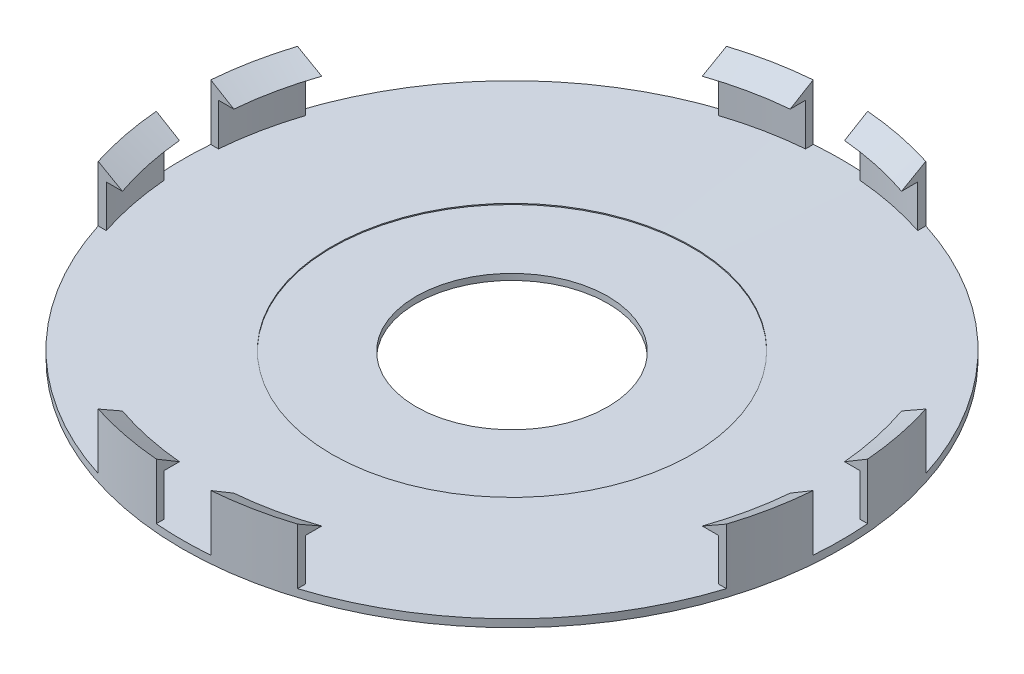
from build123d import *
from build123d.topology import SkipClean

# Parameters (mm, degrees)
CUT_EXTRUDE_1_REACH = 63.375
SKETCH_3_W          = 7.1
SKETCH_3_H          = 24.266407169
SKETCH_3_W_2        = 24.266407169
SKETCH_3_H_2        = 7.1
SKETCH_4_R          = 23.5
CUT_EXTRUDE_2_DEPTH = 7.5


with BuildPart() as part:
    # Эскиз2 → Повернуть1 (revolve)
    with BuildSketch(Plane.XY, mode=Mode.PRIVATE) as revolve_1_sk:
        Polygon((12.5, 0), (12.5, 0.896852554), (42, 1), (42, 6.5), (40, 6.5), (43, 8.3), (43, 0), align=None)
    revolve(revolve_1_sk.sketch.rotate(Axis((0, -20.602437041, 0), (0, 1, 0)), 90), axis=Axis((0, -20.602437041, 0), (0, 1, 0)))

    # Вырез-Вытянуть1: up to this cone (the profile starts inside it)
    with SkipClean():  # the faces are left unmerged after this step: merging them gives an invalid solid
        cut_extrude_1_end = Plane(origin=(0, 8.3, 0), z_dir=(0, 1, 0)).offset(-7.446852991) * Cone(0.000285998, 629513.797627356, 2201.109848989, align=(Align.CENTER, Align.CENTER, Align.MIN), mode=Mode.PRIVATE)
        # Эскиз3 → Вырез-Вытянуть1 (cut, up to the surface)
        with BuildSketch(Plane(origin=(0, 8.3, 0), x_dir=(1, 0, 0), z_dir=(0, 1, 0)), mode=Mode.PRIVATE) as cut_extrude_1_sk1:
            Polygon((-13, -13), (-53, -13), (-13, -53), align=None)
        cut_extrude_1_tool1 = extrude(cut_extrude_1_sk1.sketch, amount=-CUT_EXTRUDE_1_REACH, mode=Mode.PRIVATE) & cut_extrude_1_end
        add(cut_extrude_1_tool1.solids().sort_by_distance((-26.333333, 8.3, 26.333333))[0], mode=Mode.SUBTRACT)
        # Эскиз3 → Вырез-Вытянуть1 (cut, up to the surface)
        with BuildSketch(Plane(origin=(0, 8.3, 0), x_dir=(1, 0, 0), z_dir=(0, 1, 0)), mode=Mode.PRIVATE) as cut_extrude_1_sk2:
            Polygon((-13, 13), (-13, 53), (-53, 13), align=None)
        cut_extrude_1_tool2 = extrude(cut_extrude_1_sk2.sketch, amount=-CUT_EXTRUDE_1_REACH, mode=Mode.PRIVATE) & cut_extrude_1_end
        add(cut_extrude_1_tool2.solids().sort_by_distance((-26.333333, 8.3, -26.333333))[0], mode=Mode.SUBTRACT)
        # Эскиз3 → Вырез-Вытянуть1 (cut, up to the surface)
        with BuildSketch(Plane(origin=(0, 8.3, 0), x_dir=(1, 0, 0), z_dir=(0, 1, 0)), mode=Mode.PRIVATE) as cut_extrude_1_sk3:
            Polygon((13, 13), (53, 13), (13, 53), align=None)
        cut_extrude_1_tool3 = extrude(cut_extrude_1_sk3.sketch, amount=-CUT_EXTRUDE_1_REACH, mode=Mode.PRIVATE) & cut_extrude_1_end
        add(cut_extrude_1_tool3.solids().sort_by_distance((26.333333, 8.3, -26.333333))[0], mode=Mode.SUBTRACT)
        # Эскиз3 → Вырез-Вытянуть1 (cut, up to the surface)
        with BuildSketch(Plane(origin=(0, 8.3, 0), x_dir=(1, 0, 0), z_dir=(0, 1, 0)), mode=Mode.PRIVATE) as cut_extrude_1_sk4:
            Polygon((13, -13), (13, -53), (53, -13), align=None)
        cut_extrude_1_tool4 = extrude(cut_extrude_1_sk4.sketch, amount=-CUT_EXTRUDE_1_REACH, mode=Mode.PRIVATE) & cut_extrude_1_end
        add(cut_extrude_1_tool4.solids().sort_by_distance((26.333333, 8.3, 26.333333))[0], mode=Mode.SUBTRACT)
        # Эскиз3 → Вырез-Вытянуть1 (cut, up to the surface)
        with BuildSketch(Plane(origin=(0, 8.3, 0), x_dir=(1, 0, 0), z_dir=(0, 1, 0)), mode=Mode.PRIVATE) as cut_extrude_1_sk5:
            with Locations((0, 40.866796416)):
                Rectangle(SKETCH_3_W, SKETCH_3_H)
        cut_extrude_1_tool5 = extrude(cut_extrude_1_sk5.sketch, amount=-CUT_EXTRUDE_1_REACH, mode=Mode.PRIVATE) & cut_extrude_1_end
        add(cut_extrude_1_tool5.solids().sort_by_distance((0, 8.3, -40.866796))[0], mode=Mode.SUBTRACT)
        # Эскиз3 → Вырез-Вытянуть1 (cut, up to the surface)
        with BuildSketch(Plane(origin=(0, 8.3, 0), x_dir=(1, 0, 0), z_dir=(0, 1, 0)), mode=Mode.PRIVATE) as cut_extrude_1_sk6:
            with Locations((-40.866796416, 0)):
                Rectangle(SKETCH_3_W_2, SKETCH_3_H_2)
        cut_extrude_1_tool6 = extrude(cut_extrude_1_sk6.sketch, amount=-CUT_EXTRUDE_1_REACH, mode=Mode.PRIVATE) & cut_extrude_1_end
        add(cut_extrude_1_tool6.solids().sort_by_distance((-40.866796, 8.3, 0))[0], mode=Mode.SUBTRACT)
        # Эскиз3 → Вырез-Вытянуть1 (cut, up to the surface)
        with BuildSketch(Plane(origin=(0, 8.3, 0), x_dir=(1, 0, 0), z_dir=(0, 1, 0)), mode=Mode.PRIVATE) as cut_extrude_1_sk7:
            with Locations((40.866796416, 0)):
                Rectangle(SKETCH_3_W_2, SKETCH_3_H_2)
        cut_extrude_1_tool7 = extrude(cut_extrude_1_sk7.sketch, amount=-CUT_EXTRUDE_1_REACH, mode=Mode.PRIVATE) & cut_extrude_1_end
        add(cut_extrude_1_tool7.solids().sort_by_distance((40.866796, 8.3, 0))[0], mode=Mode.SUBTRACT)
        # Эскиз3 → Вырез-Вытянуть1 (cut, up to the surface)
        with BuildSketch(Plane(origin=(0, 8.3, 0), x_dir=(1, 0, 0), z_dir=(0, 1, 0)), mode=Mode.PRIVATE) as cut_extrude_1_sk8:
            with Locations((0, -40.866796416)):
                Rectangle(SKETCH_3_W, SKETCH_3_H)
        cut_extrude_1_tool8 = extrude(cut_extrude_1_sk8.sketch, amount=-CUT_EXTRUDE_1_REACH, mode=Mode.PRIVATE) & cut_extrude_1_end
        add(cut_extrude_1_tool8.solids().sort_by_distance((0, 8.3, 40.866796))[0], mode=Mode.SUBTRACT)

    # Эскиз4 → Вырез-Вытянуть2 (cut)
    with SkipClean():  # the faces are left unmerged after this step: merging them gives an invalid solid
        with BuildSketch(Plane(origin=(0, 8.3, 0), x_dir=(1, 0, 0), z_dir=(0, 1, 0))):
            with Locations(Location((0, 0, 0), (0, 0, 270))):
                Circle(SKETCH_4_R)
        extrude(amount=-CUT_EXTRUDE_2_DEPTH, mode=Mode.SUBTRACT)


solid = part.part
